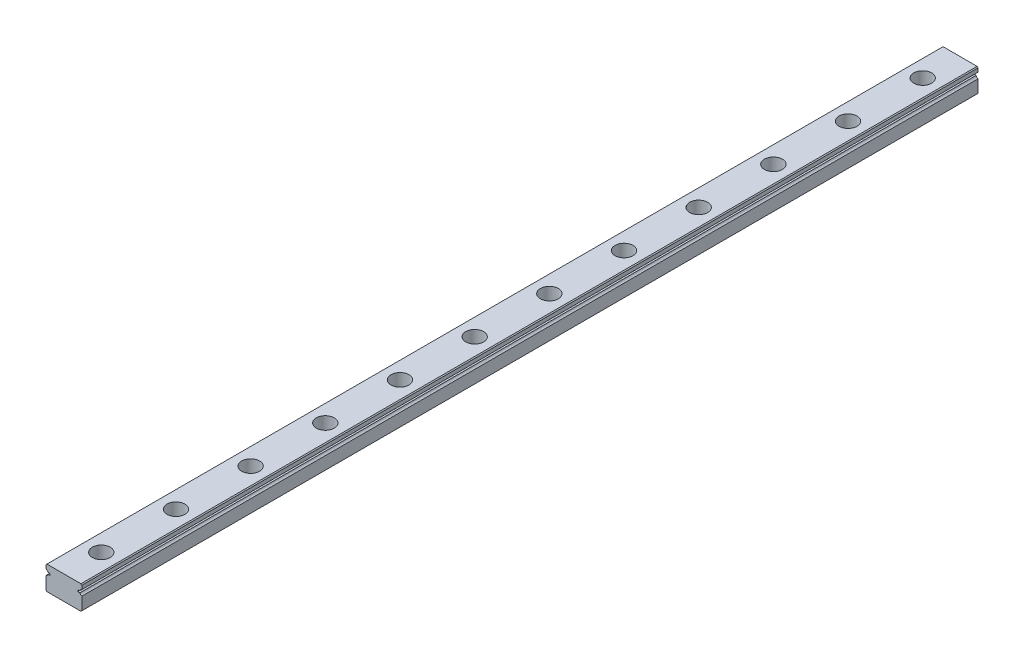
from build123d import *

# Parameters (mm, degrees)
EXTRUDE_1_DEPTH        = 300
SKETCH_2_R             = 3
SKETCH_2_R_2           = 1.75
CUT_EXTRUDE_1_DEPTH    = 4.5
SKETCH_2_2_R           = 1.75
CUT_EXTRUDE_2_DEPTH    = 9
PATTERN_LINEAR_1_COUNT = 12
PATTERN_LINEAR_1_PITCH = 25


with BuildPart() as part:
    # Sketch 1 → Extrude 1 (new body)
    with BuildSketch(Plane.XY):
        with BuildLine():
            Line((-6, 3.7), (-5.7, 4))
            Line((-5.7, 4), (5.7, 4))
            Line((5.7, 4), (6, 3.7))
            Line((6, 3.7), (6, 2.451013544))
            ThreePointArc((6, 2.451013544), (5.597935912, 2.202976267), (5.354599002, 1.798050138))
            Line((5.354599002, 1.798050138), (4.643514056, 1.798050138))
            Line((4.643514056, 1.798050138), (4.643514056, 1.201949862))
            Line((4.643514056, 1.201949862), (5.354599002, 1.201949862))
            ThreePointArc((5.354599002, 1.201949862), (5.597935912, 0.797023733), (6, 0.548986456))
            Line((6, 0.548986456), (6, -3.7))
            Line((6, -3.7), (5.7, -4))
            Line((5.7, -4), (-5.7, -4))
            Line((-5.7, -4), (-6, -3.7))
            Line((-6, -3.7), (-6, 0.548986456))
            ThreePointArc((-6, 0.548986456), (-5.597935912, 0.797023733), (-5.354599002, 1.201949862))
            Line((-5.354599002, 1.201949862), (-4.643514056, 1.201949862))
            Line((-4.643514056, 1.201949862), (-4.643514056, 1.798050138))
            Line((-4.643514056, 1.798050138), (-5.354599002, 1.798050138))
            ThreePointArc((-5.354599002, 1.798050138), (-5.597935912, 2.202976267), (-6, 2.451013544))
            Line((-6, 2.451013544), (-6, 3.7))
        make_face()
    extrude(amount=EXTRUDE_1_DEPTH)

    # Sketch 2 → Cut-Extrude 1 (cut)
    with BuildSketch(Plane(origin=(0, 4, 0), x_dir=(1, 0, 0), z_dir=(0, 1, 0))):
        with Locations((0, -12.5)):
            Circle(SKETCH_2_R)
        with Locations((0, -12.5)):
            Circle(SKETCH_2_R_2, mode=Mode.SUBTRACT)
    cut_extrude_1 = extrude(amount=-CUT_EXTRUDE_1_DEPTH, mode=Mode.SUBTRACT)

    # Sketch 2_2 → Cut-Extrude 2 (cut, through all)
    with BuildSketch(Plane(origin=(0, 4, 0), x_dir=(1, 0, 0), z_dir=(0, 1, 0))):
        with Locations((0, -12.5)):
            Circle(SKETCH_2_2_R)
    cut_extrude_2 = extrude(amount=-CUT_EXTRUDE_2_DEPTH, mode=Mode.SUBTRACT)

    # Pattern Linear 1: Cut-Extrude 1, Cut-Extrude 2 ×12
    with Locations(*[(0, 0, i * PATTERN_LINEAR_1_PITCH) for i in range(1, PATTERN_LINEAR_1_COUNT)]):
        add(cut_extrude_1, mode=Mode.SUBTRACT)
        add(cut_extrude_2, mode=Mode.SUBTRACT)


solid = part.part
